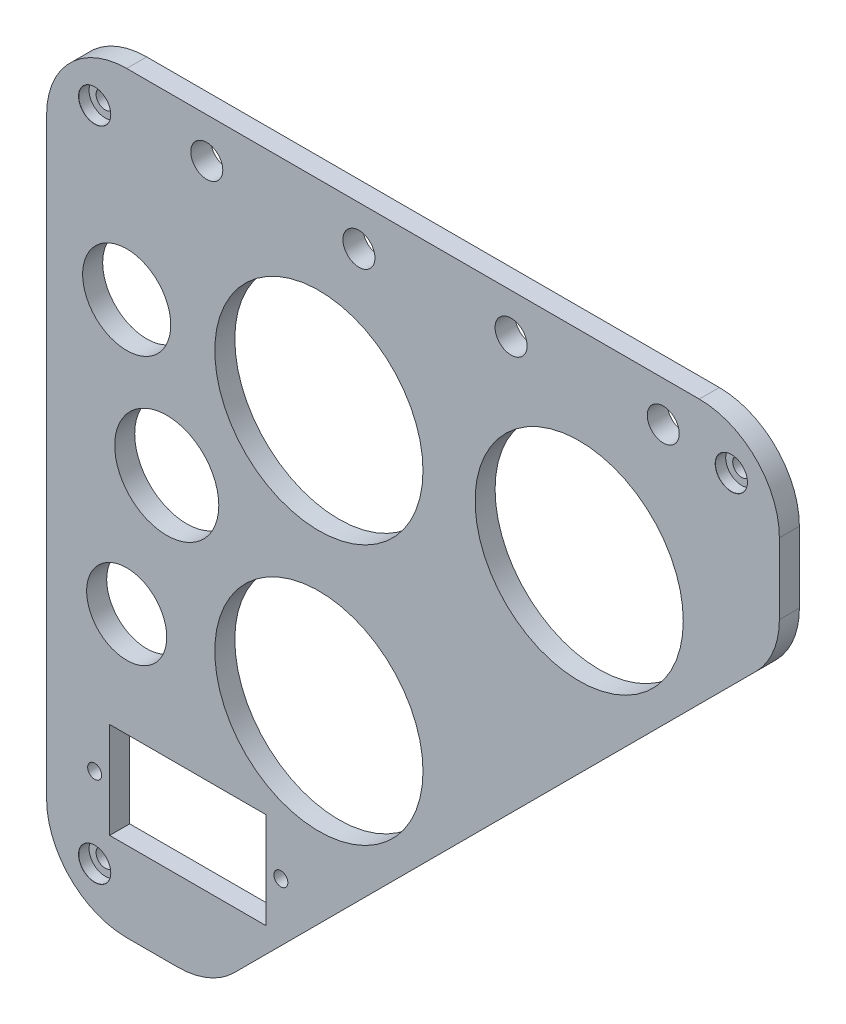
from build123d import *

# Parameters (mm, degrees)
ESTRUSIONE_ESTRUSIONE1_DEPTH                 = 5
FORO_LAMATO_PER_VITE_M4_A_TESTA_CILI_2_COUNT = 2
FORO_LAMATO_PER_VITE_M4_A_TESTA_CILI_2_PITCH = 164
FORO_LAMATO_PER_VITE_M4_A_TESTA_CILI_3_COUNT = 2
FORO_LAMATO_PER_VITE_M4_A_TESTA_CILI_3_PITCH = 159
SCHIZZO5_R                                   = 1.75
SCHIZZO5_R_2                                 = 10
SCHIZZO5_R_3                                 = 11
SCHIZZO5_R_4                                 = 13
SCHIZZO5_R_5                                 = 4
SCHIZZO5_R_6                                 = 26
SCHIZZO5_W                                   = 39
SCHIZZO5_H                                   = 24
TAGLIO_ESTRUSIONE2_DEPTH                     = 7


with BuildPart() as part:
    # Schizzo1 → Estrusione-Estrusione1 (new body)
    with BuildSketch(Plane.XY):
        with BuildLine():
            Line((0, 20), (0, 168))
            ThreePointArc((0, 168), (5.857864376, 182.142135624), (20, 188))
            Line((20, 188), (163, 188))
            ThreePointArc((163, 188), (177.142135624, 182.142135624), (183, 168))
            Line((183, 168), (183, 150.284271247))
            ThreePointArc((183, 150.284271247), (181.47759065, 142.6306026), (177.142135624, 136.142135624))
            Line((177.142135624, 136.142135624), (46.857864376, 5.857864376))
            ThreePointArc((46.857864376, 5.857864376), (40.3693974, 1.52240935), (32.715728753, 0))
            Line((32.715728753, 0), (20, 0))
            ThreePointArc((20, 0), (5.857864376, 5.857864376), (0, 20))
        make_face()
    extrude(amount=ESTRUSIONE_ESTRUSIONE1_DEPTH)

    # Schizzo4 → Foro lamato per Vite M4 a testa cilindrica piana-1 (revolve, cut)
    with BuildSketch(Plane(origin=(12, 176, 5), x_dir=(0, -1, 0), z_dir=(1, 0, 0))):
        Polygon((0, 0), (0, 5), (2.25, 5), (2.25, 2.6), (4, 2.6), (4, 0.025), (4.025, 0), align=None)
    foro_lamato_per_vite_m4_a_testa_cilindri = revolve(axis=Axis((12, 176, 11.35), (0, 0, -1)), mode=Mode.SUBTRACT)

    # Foro lamato per Vite M4 a testa cili 2: Foro lamato per Vite M4 a testa cilindrica piana-1 ×2
    with Locations(*[(0, -i * FORO_LAMATO_PER_VITE_M4_A_TESTA_CILI_2_PITCH, 0) for i in range(1, FORO_LAMATO_PER_VITE_M4_A_TESTA_CILI_2_COUNT)]):
        add(foro_lamato_per_vite_m4_a_testa_cilindri, mode=Mode.SUBTRACT)

    # Foro lamato per Vite M4 a testa cili 3: Foro lamato per Vite M4 a testa cilindrica piana-1 ×2
    with Locations(*[(i * FORO_LAMATO_PER_VITE_M4_A_TESTA_CILI_3_PITCH, 0, 0) for i in range(1, FORO_LAMATO_PER_VITE_M4_A_TESTA_CILI_3_COUNT)]):
        add(foro_lamato_per_vite_m4_a_testa_cilindri, mode=Mode.SUBTRACT)

    # Schizzo5 → Taglio-Estrusione2 (cut)
    with BuildSketch(Plane.XY.offset(5)):
        with Locations((12, 32)):
            Circle(SCHIZZO5_R)
        with Locations((58.5, 32)):
            Circle(SCHIZZO5_R)
        with Locations((20, 70)):
            Circle(SCHIZZO5_R_2)
        with Locations((20, 138)):
            Circle(SCHIZZO5_R_3)
        with Locations((30, 105)):
            Circle(SCHIZZO5_R_4)
        with Locations((40, 178)):
            Circle(SCHIZZO5_R_5)
        with Locations((78, 178)):
            Circle(SCHIZZO5_R_5)
        with Locations((116, 178)):
            Circle(SCHIZZO5_R_5)
        with Locations((154, 178)):
            Circle(SCHIZZO5_R_5)
        with Locations((68, 138)):
            Circle(SCHIZZO5_R_6)
        with Locations((133, 138)):
            Circle(SCHIZZO5_R_6)
        with Locations((68, 73)):
            Circle(SCHIZZO5_R_6)
        with Locations((35.25, 32)):
            Rectangle(SCHIZZO5_W, SCHIZZO5_H)
    extrude(amount=-TAGLIO_ESTRUSIONE2_DEPTH, mode=Mode.SUBTRACT)


solid = part.part
